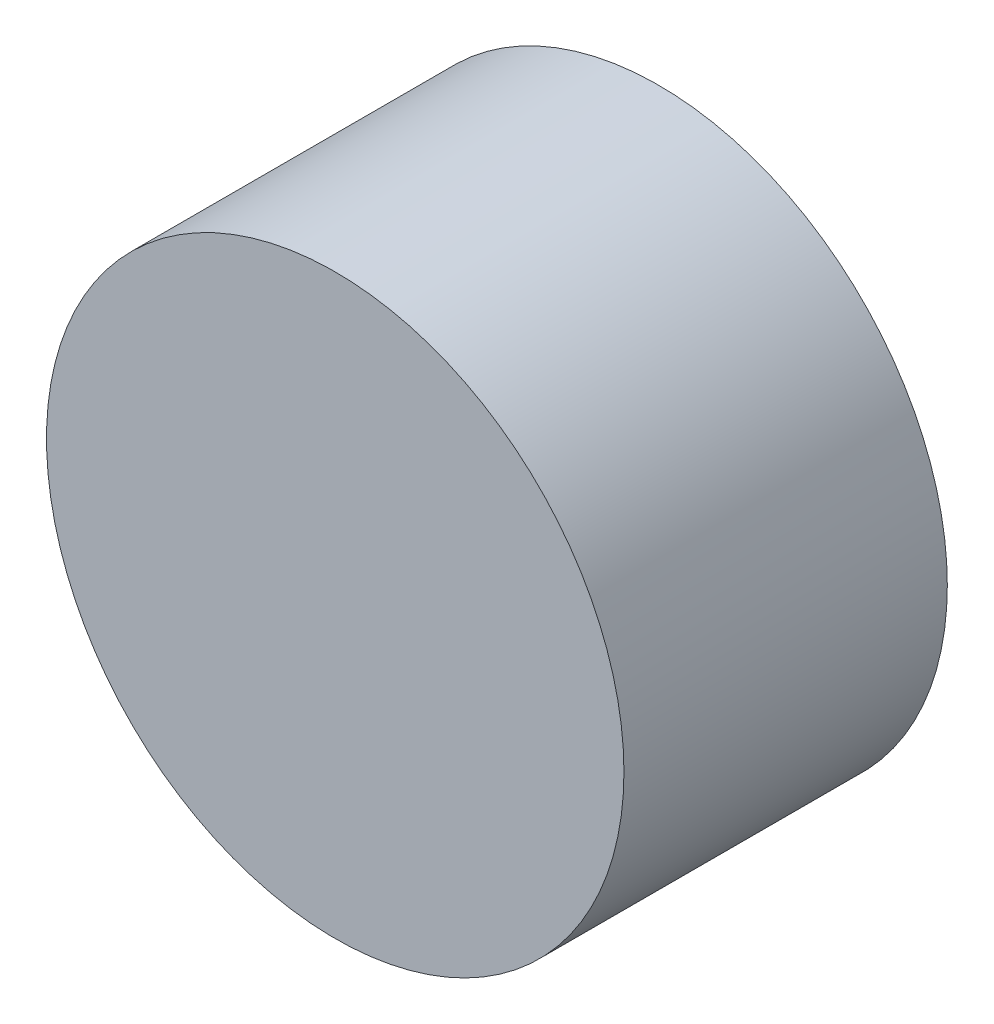
from build123d import *

# Parameters (mm, degrees)
SKETCH1_R           = 25
BOSS_EXTRUDE1_DEPTH = 28


with BuildPart() as part:
    # Sketch1 → Boss-Extrude1 (new body)
    with BuildSketch(Plane.XY):
        Circle(SKETCH1_R)
    extrude(amount=BOSS_EXTRUDE1_DEPTH)


solid = part.part
